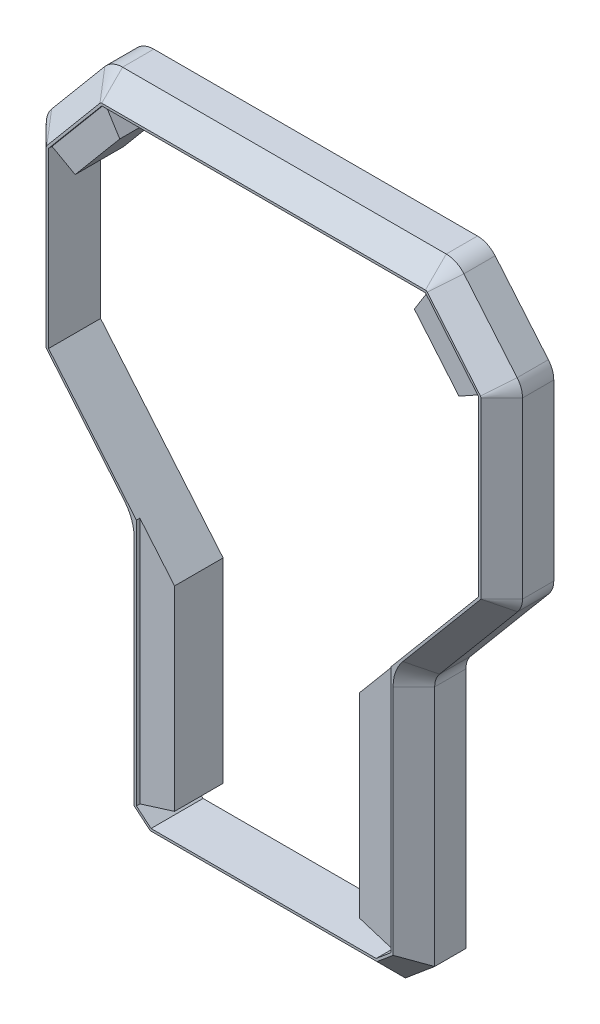
from build123d import *

# Parameters (mm, degrees)
RESSALTO_EXTRUS_O1_DEPTH = 22.5
CHANFRO1_SIZE            = 9
CORTE_EXTRUS_O1_REACH    = 24.5
ESBO_O3_W                = 1139.230904301
ESBO_O3_H                = 709.798033895
CORTE_EXTRUS_O5_DEPTH    = 1.5
CORTE_EXTRUS_O6_REACH    = 23


with BuildPart() as part:
    # Esboço1 → Ressalto-extrusão1 (new body, symmetric)
    with BuildSketch(Plane.XY):
        with BuildLine():
            Line((-69.991831819, 290.260059805), (69.991831819, 290.260059805))
            ThreePointArc((69.991831819, 290.260059805), (74.218014437, 289.323137676), (77.652276251, 286.687935902))
            Line((77.652276251, 286.687935902), (100.660444431, 259.267868814))
            ThreePointArc((100.660444431, 259.267868814), (102.396926208, 256.26019415), (103, 252.839992717))
            Line((103, 252.839992717), (103, 177.526516487))
            ThreePointArc((103, 177.526516487), (102.453136861, 174.425101506), (100.878507208, 171.697762944))
            Line((100.878507208, 171.697762944), (67.121492792, 131.46771974))
            ThreePointArc((67.121492792, 131.46771974), (65.546863139, 128.740381178), (65, 125.638966197))
            Line((65, 125.638966197), (65, 20.90019601))
            Line((65, 20.90019601), (52.319579452, 10.260059805))
            Line((52.319579452, 10.260059805), (-52.319579452, 10.260059805))
            Line((-52.319579452, 10.260059805), (-65, 20.90019601))
            Line((-65, 20.90019601), (-65, 125.638966197))
            ThreePointArc((-65, 125.638966197), (-65.546863139, 128.740381178), (-67.121492792, 131.46771974))
            Line((-67.121492792, 131.46771974), (-100.878507208, 171.697762944))
            ThreePointArc((-100.878507208, 171.697762944), (-102.453136861, 174.425101506), (-103, 177.526516487))
            Line((-103, 177.526516487), (-103, 252.839992717))
            ThreePointArc((-103, 252.839992717), (-102.396926208, 256.26019415), (-100.660444431, 259.267868814))
            Line((-100.660444431, 259.267868814), (-77.652276251, 286.687935902))
            ThreePointArc((-77.652276251, 286.687935902), (-74.218014437, 289.323137676), (-69.991831819, 290.260059805))
        make_face()
        Polygon((-63.705668081, 270.260059805), (63.705668081, 270.260059805), (83, 247.265970424), (83, 181.505464287), (40, 130.260059805), (40, 30.260059805), (-40, 30.260059805), (-40, 130.260059805), (-83, 181.505464287), (-83, 247.265970424), align=None, mode=Mode.SUBTRACT)
    extrude(amount=RESSALTO_EXTRUS_O1_DEPTH, both=True)

    # Chanfro1
    chanfro1_edges = [part.edges().sort_by_distance(p)[0] for p in [
        (65, 73.269581104, 22.5),
        (65.546863139, 128.740381178, 22.5),
        (84, 151.582741342, 22.5),
        (102.453136861, 174.425101506, 22.5),
        (103, 215.183254602, 22.5),
        (102.396926208, 256.26019415, 22.5),
        (89.156360341, 272.977902358, 22.5),
        (74.218014437, 289.323137676, 22.5),
        (0, 290.260059805, 22.5),
        (-74.218014437, 289.323137676, 22.5),
        (-89.156360341, 272.977902358, 22.5),
        (-102.396926208, 256.26019415, 22.5),
        (-103, 215.183254602, 22.5),
        (-102.453136861, 174.425101506, 22.5),
        (-84, 151.582741342, 22.5),
        (-65.546863139, 128.740381178, 22.5),
        (-65, 73.269581104, 22.5),
        (-58.659789726, 15.580127908, 22.5),
        (0, 10.260059805, 22.5),
        (58.659789726, 15.580127908, 22.5),
    ]]
    chamfer(chanfro1_edges, length=CHANFRO1_SIZE)

    # Esboço3 → Corte-extrusão1 (cut, up to next)
    with BuildSketch(Plane.XY, mode=Mode.PRIVATE) as corte_extrus_o1_sk1:
        with Locations((-153.157436203, 152.53565808)):
            Rectangle(ESBO_O3_W, ESBO_O3_H)
    corte_extrus_o1_tool1 = extrude(corte_extrus_o1_sk1.sketch, amount=-CORTE_EXTRUS_O1_REACH, mode=Mode.PRIVATE) & part.part
    add(corte_extrus_o1_tool1.solids().sort_by_distance((-153.157436, 152.535658, 0))[0], mode=Mode.SUBTRACT)

    # Esboço4 → Corte-extrusão5 (cut)
    with BuildSketch(Plane.XY.offset(22.5)):
        Polygon((69.991831819, 280.260059805), (-69.991831819, 280.260059805), (-93, 252.839992717), (-93, 177.865761944), (-55, 132.579125426), (-55, 25.563272592), (-48.679877109, 20.260059805), (48.679877109, 20.260059805), (55, 25.563272592), (55, 132.579125426), (93, 177.865761944), (93, 252.839992717), align=None)
        Polygon((40, 30.260059805), (-40, 30.260059805), (-40, 130.260059805), (-83, 181.505464287), (-83, 247.265970424), (-63.705668081, 270.260059805), (63.705668081, 270.260059805), (83, 247.265970424), (83, 181.505464287), (40, 130.260059805), align=None, mode=Mode.SUBTRACT)
    extrude(amount=-CORTE_EXTRUS_O5_DEPTH, mode=Mode.SUBTRACT)

    # Esboço5 → Corte-extrusão6 (cut, up to next)
    with BuildSketch(Plane.XY.offset(21), mode=Mode.PRIVATE) as corte_extrus_o6_sk1:
        Polygon((-93, 252.839992717), (-83, 247.265970424), (-83, 181.505464287), (-40, 130.260059805), (-40, 114.702821537), (-93, 177.865761944), align=None)
    corte_extrus_o6_tool1 = extrude(corte_extrus_o6_sk1.sketch, amount=-CORTE_EXTRUS_O6_REACH, mode=Mode.PRIVATE) & part.part
    add(corte_extrus_o6_tool1.solids().sort_by_distance((-88.720359, 248.760631, 21))[0], mode=Mode.SUBTRACT)
    # Esboço5 → Corte-extrusão6 (cut, up to next)
    with BuildSketch(Plane.XY.offset(21), mode=Mode.PRIVATE) as corte_extrus_o6_sk2:
        Polygon((-63.705668081, 270.260059805), (-69.991831819, 280.260059805), (69.991831819, 280.260059805), (63.705668081, 270.260059805), align=None)
    corte_extrus_o6_tool2 = extrude(corte_extrus_o6_sk2.sketch, amount=-CORTE_EXTRUS_O6_REACH, mode=Mode.PRIVATE) & part.part
    add(corte_extrus_o6_tool2.solids().sort_by_distance((0, 275.338423, 21))[0], mode=Mode.SUBTRACT)
    # Esboço5 → Corte-extrusão6 (cut, up to next)
    with BuildSketch(Plane.XY.offset(21), mode=Mode.PRIVATE) as corte_extrus_o6_sk3:
        Polygon((-55, 25.563272592), (-40, 30.260059805), (40, 30.260059805), (55, 25.563272592), (48.679877109, 20.260059805), (-48.679877109, 20.260059805), align=None)
    corte_extrus_o6_tool3 = extrude(corte_extrus_o6_sk3.sketch, amount=-CORTE_EXTRUS_O6_REACH, mode=Mode.PRIVATE) & part.part
    add(corte_extrus_o6_tool3.solids().sort_by_distance((0, 25.125903, 21))[0], mode=Mode.SUBTRACT)
    # Esboço5 → Corte-extrusão6 (cut, up to next)
    with BuildSketch(Plane.XY.offset(21), mode=Mode.PRIVATE) as corte_extrus_o6_sk4:
        Polygon((40, 114.702821537), (93, 177.865761944), (93, 252.839992717), (83, 247.265970424), (83, 181.505464287), (40, 130.260059805), align=None)
    corte_extrus_o6_tool4 = extrude(corte_extrus_o6_sk4.sketch, amount=-CORTE_EXTRUS_O6_REACH, mode=Mode.PRIVATE) & part.part
    add(corte_extrus_o6_tool4.solids().sort_by_distance((65.366594, 147.235332, 21))[0], mode=Mode.SUBTRACT)


solid = part.part
